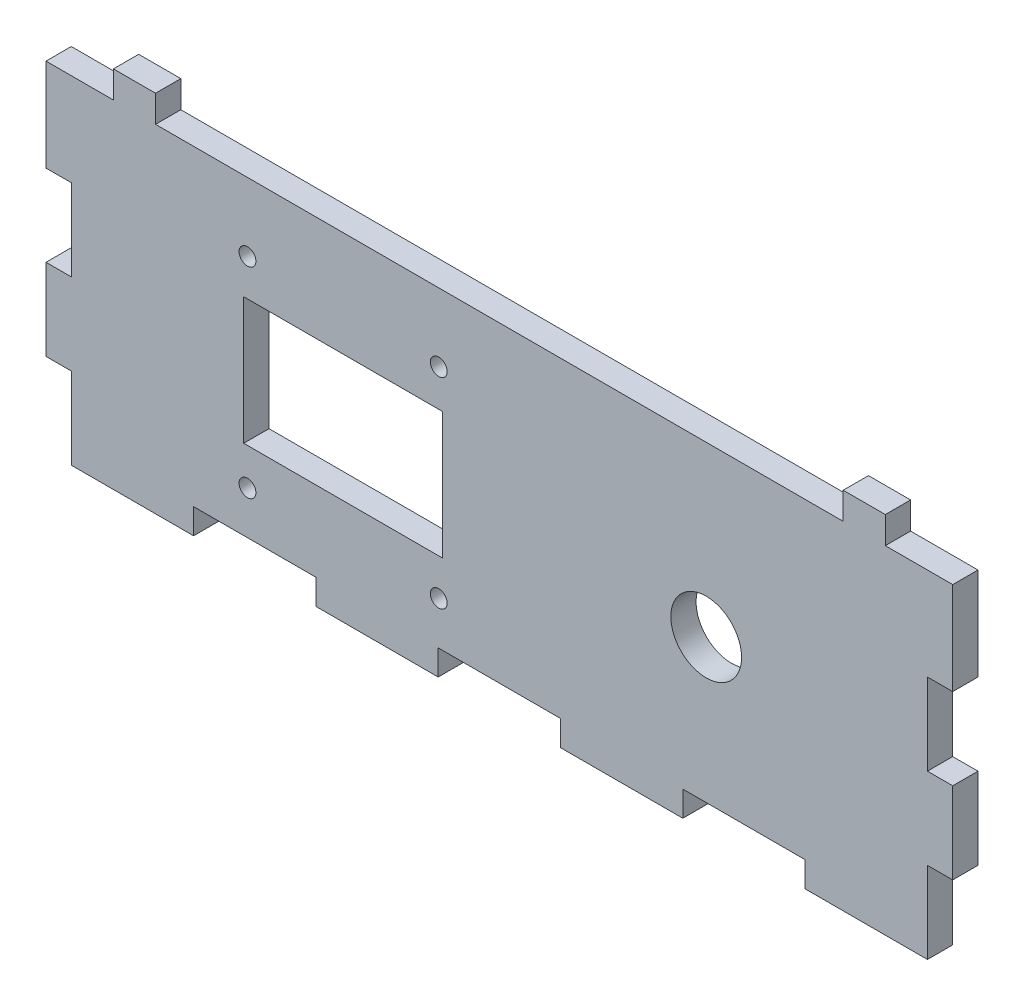
from build123d import *

# Parameters (mm, degrees)
CROQUIS1_R              = 1
CROQUIS1_W              = 23.597249427
CROQUIS1_H              = 15.06
CROQUIS1_R_2            = 4.2
SALIENTE_EXTRUIR1_DEPTH = 3


with BuildPart() as part:
    # Croquis1 → Saliente-Extruir1 (new body)
    with BuildSketch(Plane.XY):
        Polygon((-333.002689238, 38.183153475), (-318.486974952, 38.183153475), (-318.486974952, 47.861153475), (-315.486974952, 47.861153475), (-315.486974952, 57.539153475), (-318.486974952, 57.539153475), (-318.486974952, 67.217153475), (-315.486974952, 67.217153475), (-315.486974952, 78.217153475), (-318.486974952, 78.217153475), (-323.486974952, 78.217153475), (-323.486974952, 81.417153475), (-328.486974952, 81.417153475), (-328.486974952, 78.217153475), (-410.096974952, 78.217153475), (-410.096974952, 81.417153475), (-415.096974952, 81.417153475), (-415.096974952, 78.217153475), (-420.096974952, 78.217153475), (-423.096974952, 78.217153475), (-423.096974952, 67.217153475), (-420.096974952, 67.217153475), (-420.096974952, 57.539153475), (-423.096974952, 57.539153475), (-423.096974952, 47.861153475), (-420.096974952, 47.861153475), (-420.096974952, 38.183153475), (-405.581260666, 38.183153475), (-405.581260666, 41.183153475), (-391.06554638, 41.183153475), (-391.06554638, 38.183153475), (-376.549832095, 38.183153475), (-376.549832095, 41.183153475), (-362.034117809, 41.183153475), (-362.034117809, 38.183153475), (-347.518403523, 38.183153475), (-347.518403523, 41.183153475), (-333.002689238, 41.183153475), align=None)
        with Locations((-399.183395748, 46.300153475)):
            Circle(CROQUIS1_R, mode=Mode.SUBTRACT)
        with Locations((-387.833395749, 58.200153475)):
            Rectangle(CROQUIS1_W, CROQUIS1_H, mode=Mode.SUBTRACT)
        with Locations((-376.483395748, 46.300153475)):
            Circle(CROQUIS1_R, mode=Mode.SUBTRACT)
        with Locations((-344.743963788, 58.200153475)):
            Circle(CROQUIS1_R_2, mode=Mode.SUBTRACT)
        with Locations((-399.183395748, 70.100153475)):
            Circle(CROQUIS1_R, mode=Mode.SUBTRACT)
        with Locations((-376.483395748, 70.100153475)):
            Circle(CROQUIS1_R, mode=Mode.SUBTRACT)
    extrude(amount=SALIENTE_EXTRUIR1_DEPTH)


solid = part.part
